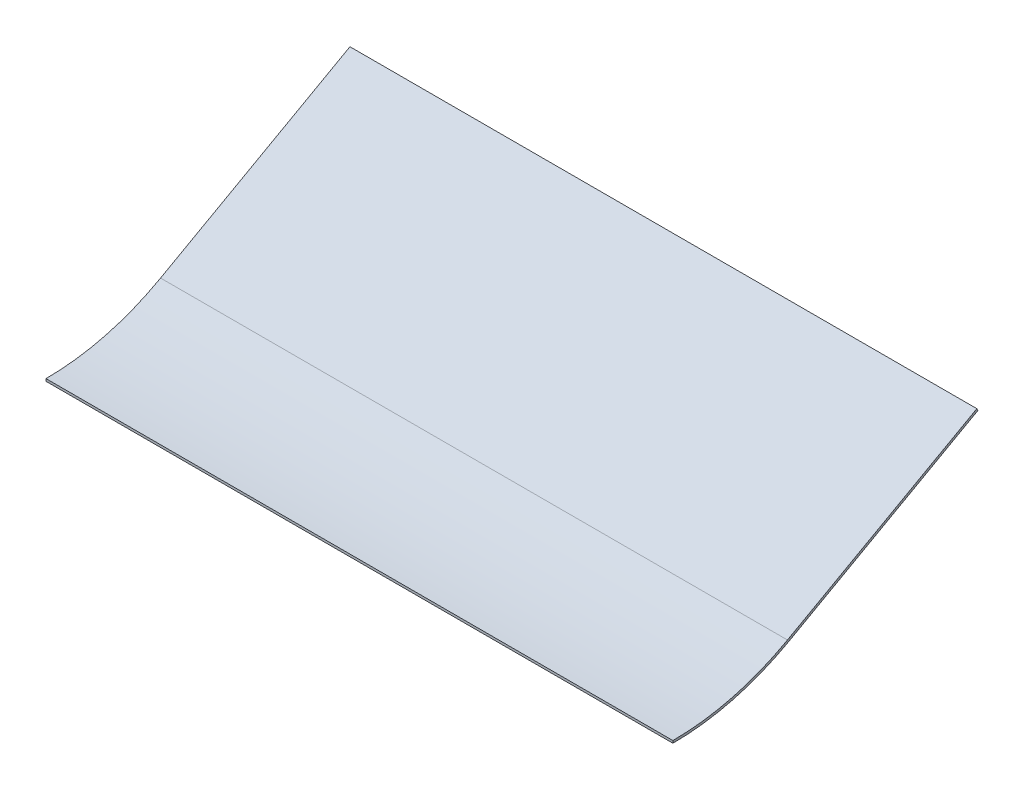
from build123d import *

# Parameters (mm, degrees)
EXTRUDE_THIN1_DEPTH = 419.1


with BuildPart() as part:
    # Sketch1 → Extrude-Thin1 (new body)
    with BuildSketch(Plane(origin=(0, 0, 0), x_dir=(0, 0, -1), z_dir=(1, 0, 0))):
        with BuildLine():
            Line((203.2, -66.687592446), (76.590395696, -137.309600404))
            ThreePointArc((76.590395696, -137.309600404), (39.568774576, -152.165459795), (0, -157.226))
            Line((0, -157.226), (0, -158.8135))
            ThreePointArc((0, -158.8135), (39.968297744, -153.701863872), (77.3637236, -138.696005901))
            Line((77.3637236, -138.696005901), (203.973327905, -68.073997943))
            Line((203.973327905, -68.073997943), (203.2, -66.687592446))
        make_face()
    extrude(amount=EXTRUDE_THIN1_DEPTH)


solid = part.part
